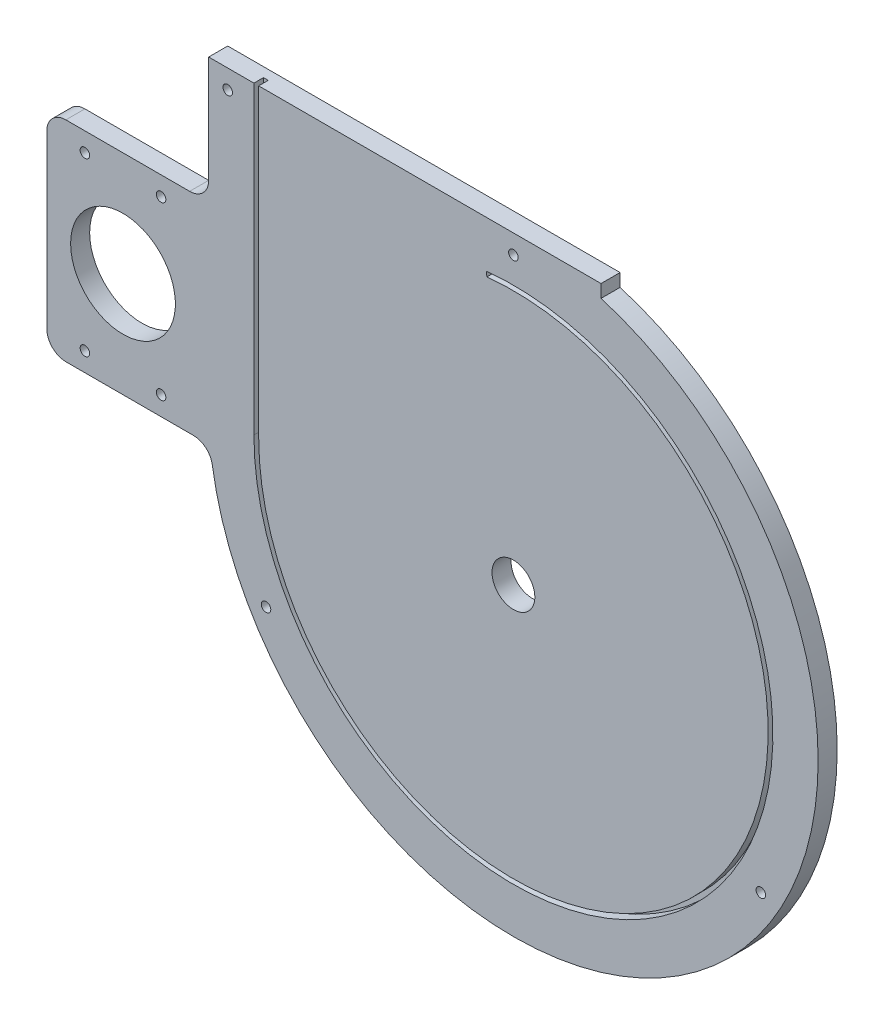
from build123d import *

# Parameters (mm, degrees)
SKETCH1_W               = 406.4
SKETCH1_H               = 406.4
SKETCH1_R               = 14.2875
BOSS_EXTRUDE1_DEPTH     = 12.7
CUT_EXTRUDE1_DEPTH      = 6.35
CUT_EXTRUDE2_DEPTH      = 13.7
SKETCH4_R               = 3.175
CUT_EXTRUDE3_DEPTH      = 1
CUT_EXTRUDE3_DEPTH_BACK = 13.7
SKETCH6_W               = 108.979085312
SKETCH6_H               = 139.7
SKETCH6_R               = 34.925
SKETCH6_R_2             = 3.175
BOSS_EXTRUDE2_DEPTH     = 12.7
FILLET1_R               = 12.7


with BuildPart() as part:
    # Sketch1 → Boss-Extrude1 (new body)
    with BuildSketch(Plane.XY):
        Rectangle(SKETCH1_W, SKETCH1_H)
        Circle(SKETCH1_R, mode=Mode.SUBTRACT)
    extrude(amount=BOSS_EXTRUDE1_DEPTH)

    # Sketch2 → Cut-Extrude1 (cut)
    with BuildSketch(Plane.XY.offset(12.7)):
        with BuildLine():
            Line((-18.027683557, 172.095842576), (-17.696900373, 168.938120694))
            ThreePointArc((-17.696900373, 168.938120694), (126.212734393, -113.68207679), (-169.8625, 0))
            Line((-169.8625, 0), (-169.8625, 203.2))
            Line((-169.8625, 203.2), (-173.0375, 203.2))
            Line((-173.0375, 203.2), (-173.0375, 0))
            ThreePointArc((-173.0375, 0), (128.571850923, -115.806975422), (-18.027683557, 172.095842576))
        make_face()
    extrude(amount=-CUT_EXTRUDE1_DEPTH, mode=Mode.SUBTRACT)

    # Sketch3 → Cut-Extrude2 (cut, through all)
    with BuildSketch(Plane.XY.offset(12.7)):
        with BuildLine():
            Line((58.432704894, 203.2), (58.432704894, 194.617211466))
            ThreePointArc((58.432704894, 194.617211466), (163.039513149, 121.278015948), (203.2, -3.13e-07))
            Line((203.2, -3.13e-07), (203.2, 203.2))
            Line((203.2, 203.2), (58.432704894, 203.2))
        make_face()
        with BuildLine():
            Line((203.2, -203.2), (203.2, -3.13e-07))
            ThreePointArc((203.2, -3.13e-07), (143.684097934, -143.68409794), (3.04e-07, -203.2))
            Line((3.04e-07, -203.2), (203.2, -203.2))
        make_face()
        with BuildLine():
            Line((-203.2, -203.2), (3.04e-07, -203.2))
            ThreePointArc((3.04e-07, -203.2), (-143.68409783, -143.684098045), (-203.2, 0))
            Line((-203.2, 0), (-203.2, -203.2))
        make_face()
    extrude(amount=-CUT_EXTRUDE2_DEPTH, mode=Mode.SUBTRACT)

    # Sketch4 → Cut-Extrude3 (cut, two sides)
    with BuildSketch(Plane.XY.offset(12.7)) as cut_extrude3_sk:
        with Locations((-190.5, 190.5)):
            Circle(SKETCH4_R)
        with Locations((-164.977839421, -95.25)):
            Circle(SKETCH4_R)
        with Locations((164.977839421, -95.25)):
            Circle(SKETCH4_R)
        with Locations((0, 190.5)):
            Circle(SKETCH4_R)
    extrude(amount=CUT_EXTRUDE3_DEPTH, mode=Mode.SUBTRACT)
    extrude(cut_extrude3_sk.sketch, amount=-CUT_EXTRUDE3_DEPTH_BACK, mode=Mode.SUBTRACT)

    # Sketch6 → Boss-Extrude2 (add, through all)
    with BuildSketch(Plane(origin=(0, 0, 0), x_dir=(-1, 0, 0), z_dir=(0, 0, -1))):
        with Locations((256.660457344, 49.425474201)):
            Rectangle(SKETCH6_W, SKETCH6_H)
        with Locations((260.35, 49.425474201)):
            Circle(SKETCH6_R, mode=Mode.SUBTRACT)
        with Locations((234.95, 106.575474201)):
            Circle(SKETCH6_R_2, mode=Mode.SUBTRACT)
        with Locations((285.75, 106.575474201)):
            Circle(SKETCH6_R_2, mode=Mode.SUBTRACT)
        with Locations((285.75, -7.724525799)):
            Circle(SKETCH6_R_2, mode=Mode.SUBTRACT)
        with Locations((234.95, -7.724525799)):
            Circle(SKETCH6_R_2, mode=Mode.SUBTRACT)
    extrude(amount=-BOSS_EXTRUDE2_DEPTH)

    # Fillet1
    fillet1_edges = [part.edges().sort_by_distance(p)[0] for p in [
        (-202.170914688, -20.424525799, 6.35),
        (-311.15, 119.275474201, 6.35),
        (-311.15, -20.424525799, 6.35),
        (-203.2, 119.275474201, 6.35),
    ]]
    fillet(fillet1_edges, radius=FILLET1_R)


solid = part.part
